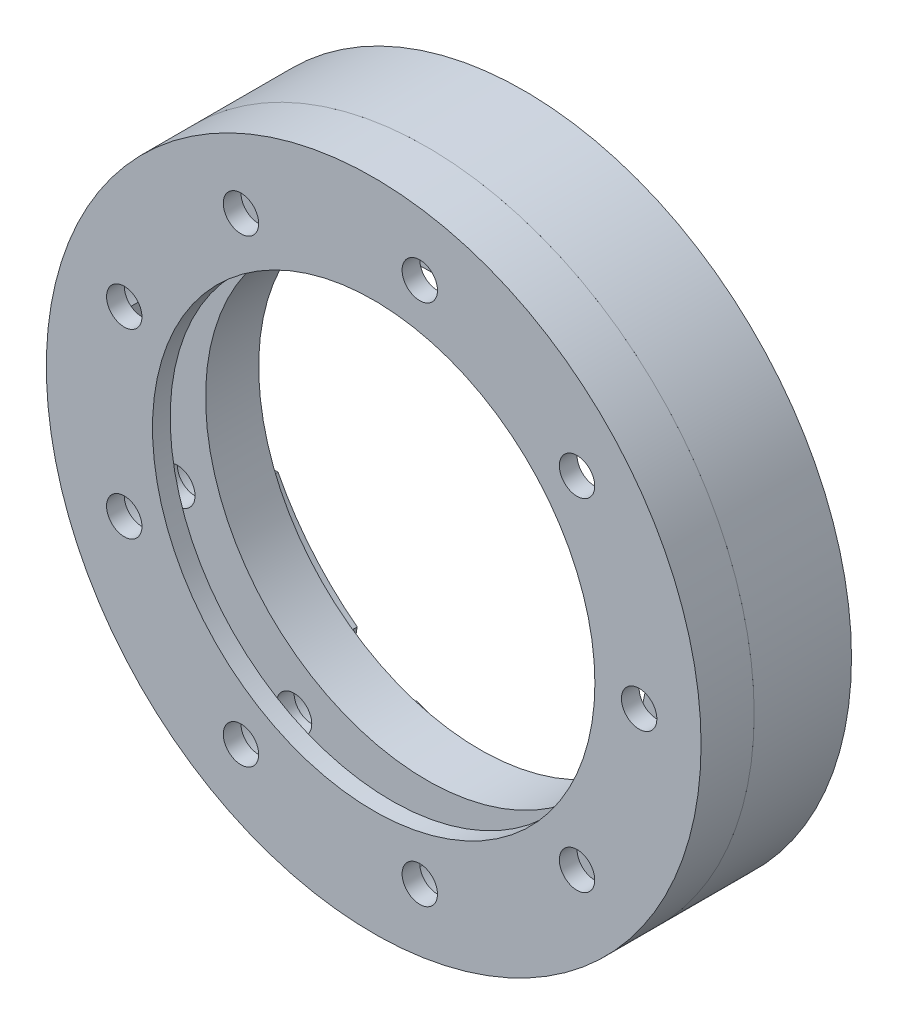
from build123d import *

# Parameters (mm, degrees)
SKETCH2_R           = 37
BOSS_EXTRUDE1_DEPTH = 6
SKETCH5_R           = 37
SKETCH5_R_2         = 31.25
BOSS_EXTRUDE2_DEPTH = 5
SKETCH6_R           = 37
SKETCH6_R_2         = 25
BOSS_EXTRUDE3_DEPTH = 6
CUT_EXTRUDE2_DEPTH  = 6
SKETCH9_R           = 2
CUT_EXTRUDE4_DEPTH  = 18
SKETCH12_R          = 4
CUT_EXTRUDE5_DEPTH  = 9
SKETCH13_R          = 25
CUT_EXTRUDE6_DEPTH  = 18
CUT_EXTRUDE7_START  = 2
SKETCH15_R          = 5.5
CUT_EXTRUDE7_DEPTH  = 4
CIRPATTERN7_COUNT   = 9
SKETCH16_R          = 32.5
CUT_EXTRUDE8_DEPTH  = 4
SKETCH17_R          = 37
CUT_EXTRUDE9_DEPTH  = 0.001


with BuildPart() as part:
    # Sketch2 → Boss-Extrude1 (new body)
    with BuildSketch(Plane.XY):
        Circle(SKETCH2_R)
    extrude(amount=BOSS_EXTRUDE1_DEPTH)

    # Sketch5 → Boss-Extrude2 (add)
    with BuildSketch(Plane.XY):
        Circle(SKETCH5_R)
        Circle(SKETCH5_R_2, mode=Mode.SUBTRACT)
    extrude(amount=-BOSS_EXTRUDE2_DEPTH)

    # Sketch6 → Boss-Extrude3 (add)
    with BuildSketch(Plane.XY.offset(6)):
        Circle(SKETCH6_R)
        Circle(SKETCH6_R_2, mode=Mode.SUBTRACT)
    extrude(amount=BOSS_EXTRUDE3_DEPTH)

    # Sketch7 → Cut-Extrude2 (cut, through all)
    with BuildSketch(Plane.XY):
        Polygon((0, 32.399276449), (0.640252712, 32.399276449), (0.640252712, 33.832341534), (1.800245239, 33.832341534), (0, 36.111190156), (-1.800245239, 33.832341534), (-0.640252712, 33.832341534), (-0.640252712, 32.399276449), align=None)
    extrude(amount=-CUT_EXTRUDE2_DEPTH, mode=Mode.SUBTRACT)

    # Sketch9 → Cut-Extrude4 (cut, through all)
    with BuildSketch(Plane.XY.offset(12)):
        with Locations((30, 0)):
            Circle(SKETCH9_R)
    cut_extrude4 = extrude(amount=-CUT_EXTRUDE4_DEPTH, mode=Mode.SUBTRACT)

    # Sketch12 → Cut-Extrude5 (cut)
    with BuildSketch(Plane(origin=(0, 0, -5), x_dir=(-1, 0, 0), z_dir=(0, 0, -1))):
        with Locations((-30, 0)):
            Circle(SKETCH12_R)
    cut_extrude5 = extrude(amount=-CUT_EXTRUDE5_DEPTH, mode=Mode.SUBTRACT)

    # Sketch13 → Cut-Extrude6 (cut, through all)
    with BuildSketch(Plane.XY.offset(12)):
        Circle(SKETCH13_R)
    extrude(amount=-CUT_EXTRUDE6_DEPTH, mode=Mode.SUBTRACT)

    # Sketch15 → Cut-Extrude7 (cut)
    with BuildSketch(Plane.XY.offset(4).offset(CUT_EXTRUDE7_START)):
        with Locations((30, 0)):
            Circle(SKETCH15_R)
    cut_extrude7 = extrude(amount=CUT_EXTRUDE7_DEPTH, mode=Mode.SUBTRACT)

    # CirPattern7: Cut-Extrude4, Cut-Extrude5, Cut-Extrude7 ×9 about axis
    cirpattern7_axis = Axis((0, 0, 0), (0, 0, 1))
    for i in range(1, CIRPATTERN7_COUNT):
        add(cut_extrude4.rotate(cirpattern7_axis, i * 360 / CIRPATTERN7_COUNT), mode=Mode.SUBTRACT)
        add(cut_extrude5.rotate(cirpattern7_axis, i * 360 / CIRPATTERN7_COUNT), mode=Mode.SUBTRACT)
        add(cut_extrude7.rotate(cirpattern7_axis, i * 360 / CIRPATTERN7_COUNT), mode=Mode.SUBTRACT)

    # Sketch16 → Cut-Extrude8 (cut)
    with BuildSketch(Plane.XY.offset(6)):
        Circle(SKETCH16_R)
    extrude(amount=CUT_EXTRUDE8_DEPTH, mode=Mode.SUBTRACT)

    # Sketch17 → Cut-Extrude9 (cut)
    with BuildSketch(Plane.XY.offset(6)):
        Circle(SKETCH17_R)
    extrude(amount=-CUT_EXTRUDE9_DEPTH, mode=Mode.SUBTRACT)


solid = part.part
